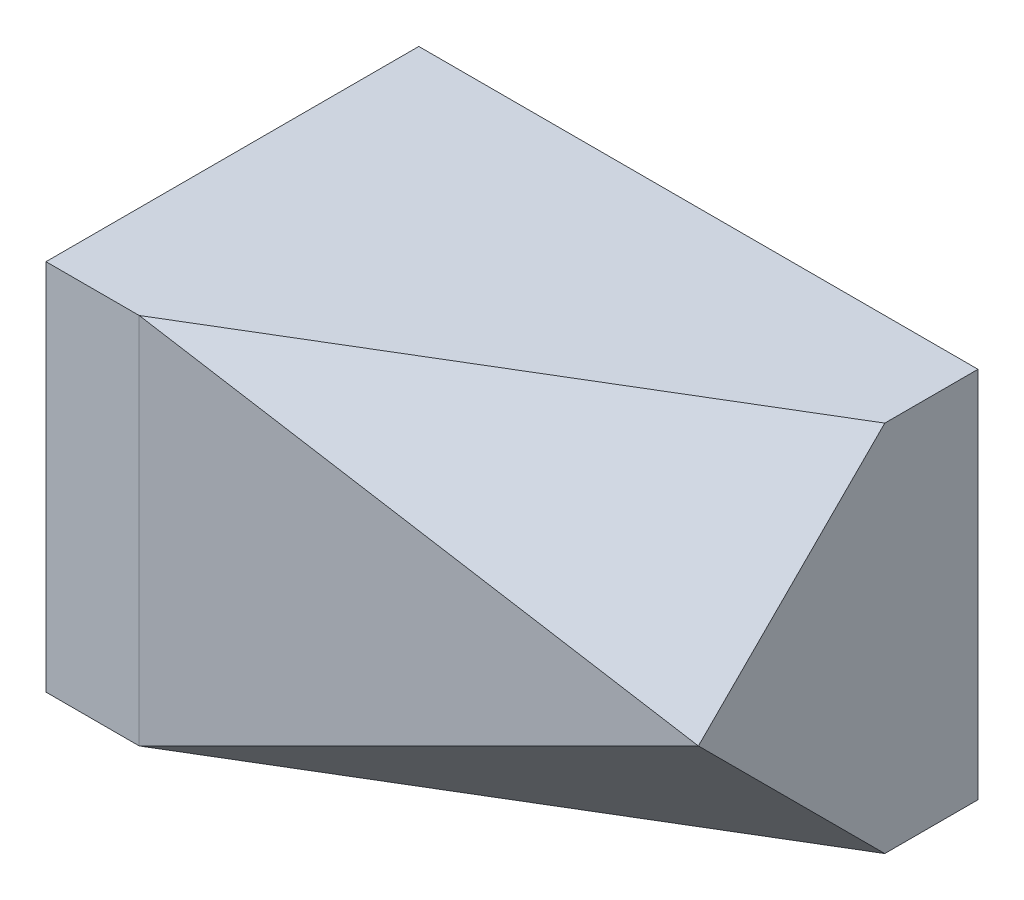
from build123d import *

# Parameters (mm, degrees)
EXTRUDE_1_DEPTH     = 20
SKETCH_4_W          = 39.68109217
SKETCH_4_H          = 19.592945183
CUT_EXTRUDE_1_DEPTH = 20
SKETCH_7_W          = 132.193091595
SKETCH_7_H          = 30.201739996
CUT_EXTRUDE_2_DEPTH = 20


with BuildPart() as part:
    # 草圖1 → 填料-伸長1 (new body)
    with BuildSketch(Plane(origin=(0, 0, 0), x_dir=(1, 0, 0), z_dir=(0, 1, 0))):
        Polygon((15, -5), (-10, -10), (-15, -10), (-15, 10), (15, 10), align=None)
    extrude(amount=EXTRUDE_1_DEPTH)

    # 草圖4 → 除料-伸長1 (cut)
    with BuildSketch(Plane(origin=(6.101694915, 10.169491525, 10.169491525), x_dir=(0.920574618, -0.276172385, -0.276172385), z_dir=(0.390566733, 0.650944555, 0.650944555))):
        with Locations((1.579314275, 10.72678571)):
            Rectangle(SKETCH_4_W, SKETCH_4_H)
    extrude(amount=CUT_EXTRUDE_1_DEPTH, mode=Mode.SUBTRACT)

    # 草圖7 → 除料-伸長2 (cut)
    with BuildSketch(Plane(origin=(1.016949153, -1.694915254, 1.694915254), x_dir=(-0.920574618, -0.276172385, 0.276172385), z_dir=(-0.390566733, 0.650944555, -0.650944555))):
        with Locations((9.754035329, 10.9182289)):
            Rectangle(SKETCH_7_W, SKETCH_7_H)
    extrude(amount=-CUT_EXTRUDE_2_DEPTH, mode=Mode.SUBTRACT)


solid = part.part
